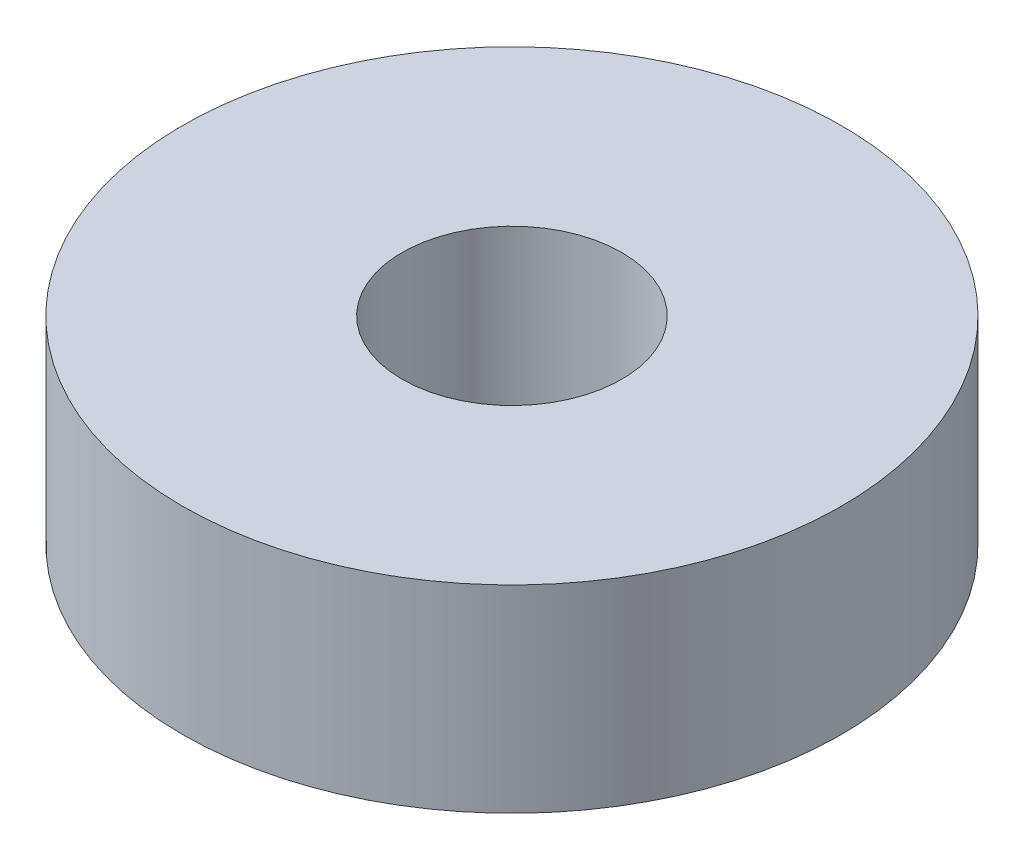
from build123d import *

# Parameters (mm, degrees)
SKETCH1_R           = 9
SKETCH1_R_2         = 3
BOSS_EXTRUDE1_DEPTH = 5.4


with BuildPart() as part:
    # Sketch1 → Boss-Extrude1 (new body)
    with BuildSketch(Plane(origin=(0, 0, 0), x_dir=(1, 0, 0), z_dir=(0, 1, 0))):
        Circle(SKETCH1_R)
        Circle(SKETCH1_R_2, mode=Mode.SUBTRACT)
    extrude(amount=BOSS_EXTRUDE1_DEPTH)


solid = part.part
